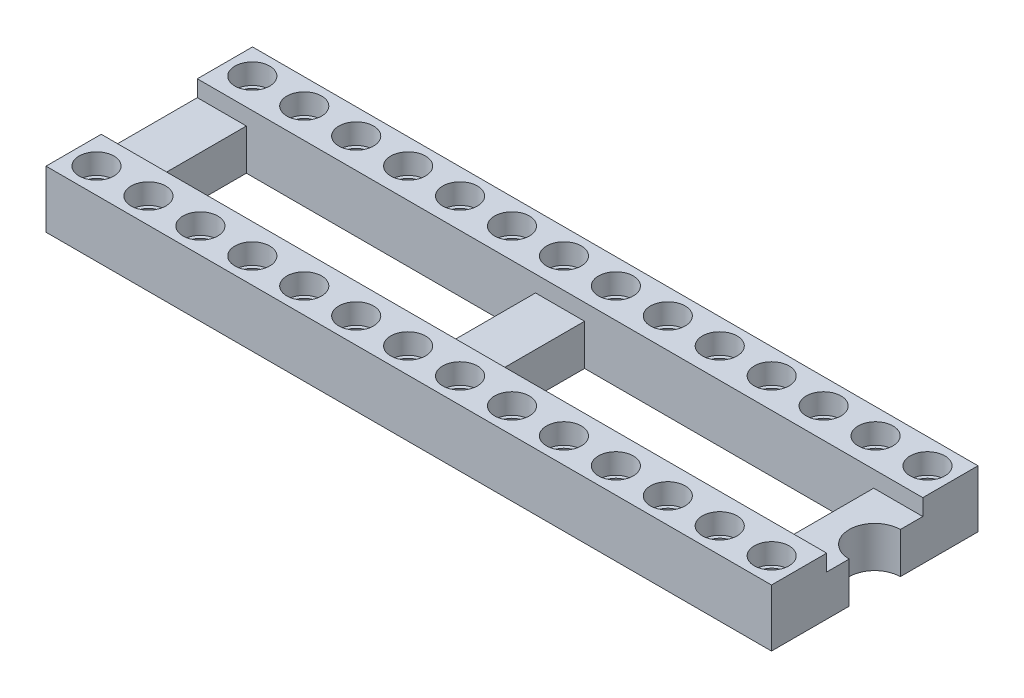
from build123d import *

# Parameters (mm, degrees)
BOSS_EXTRUDE1_DEPTH  = 17.74
SKETCH2_W            = 14.14
SKETCH2_H            = 4.7
CUT_EXTRUDE1_DEPTH   = 35.5
SKETCH3_R            = 1.25
CUT_EXTRUDE2_DEPTH   = 35.5
HOLE_D               = 1.35
HOLE_CBORE_D         = 1.7
HOLE_CBORE_DEPTH     = 1
LPATTERN1_COUNT      = 14
LPATTERN1_PITCH      = 2.54
LPATTERN1_COUNT_DIR2 = 2
LPATTERN1_PITCH_DIR2 = 7.62


with BuildPart() as part:
    # Sketch1 → Boss-Extrude1 (new body, symmetric)
    with BuildSketch(Plane(origin=(0, 0, 0), x_dir=(0, 0, -1), z_dir=(1, 0, 0))):
        Polygon((-5.05, 0), (5.05, 0), (5.05, 2.8), (2.35, 2.8), (2.35, 2), (-2.35, 2), (-2.35, 2.8), (-5.05, 2.8), align=None)
    extrude(amount=BOSS_EXTRUDE1_DEPTH, both=True)

    # Sketch2 → Cut-Extrude1 (cut)
    with BuildSketch(Plane(origin=(0, 2, 0), x_dir=(1, 0, 0), z_dir=(0, 1, 0))):
        with Locations((-8.27, 0)):
            Rectangle(SKETCH2_W, SKETCH2_H)
        with Locations((8.27, 0)):
            Rectangle(SKETCH2_W, SKETCH2_H)
    extrude(amount=-CUT_EXTRUDE1_DEPTH, mode=Mode.SUBTRACT)

    # Sketch3 → Cut-Extrude2 (cut)
    with BuildSketch(Plane(origin=(0, 2, 0), x_dir=(1, 0, 0), z_dir=(0, 1, 0))):
        with Locations((17.74, 0)):
            Circle(SKETCH3_R)
    extrude(amount=-CUT_EXTRUDE2_DEPTH, mode=Mode.SUBTRACT)

    # hole (through all)
    with Locations(Plane(origin=(0, 2.8, 0), x_dir=(1, 0, 0), z_dir=(0, 1, 0))):
        with Locations((16.51, 3.81)):
            hole = CounterBoreHole(HOLE_D / 2, HOLE_CBORE_D / 2, HOLE_CBORE_DEPTH)

    # LPattern1: hole 14 × 2
    with Locations(*[(-i * LPATTERN1_PITCH, 0, j * LPATTERN1_PITCH_DIR2) for i in range(LPATTERN1_COUNT) for j in range(LPATTERN1_COUNT_DIR2) if (i, j) != (0, 0)]):
        add(hole, mode=Mode.SUBTRACT)


solid = part.part
